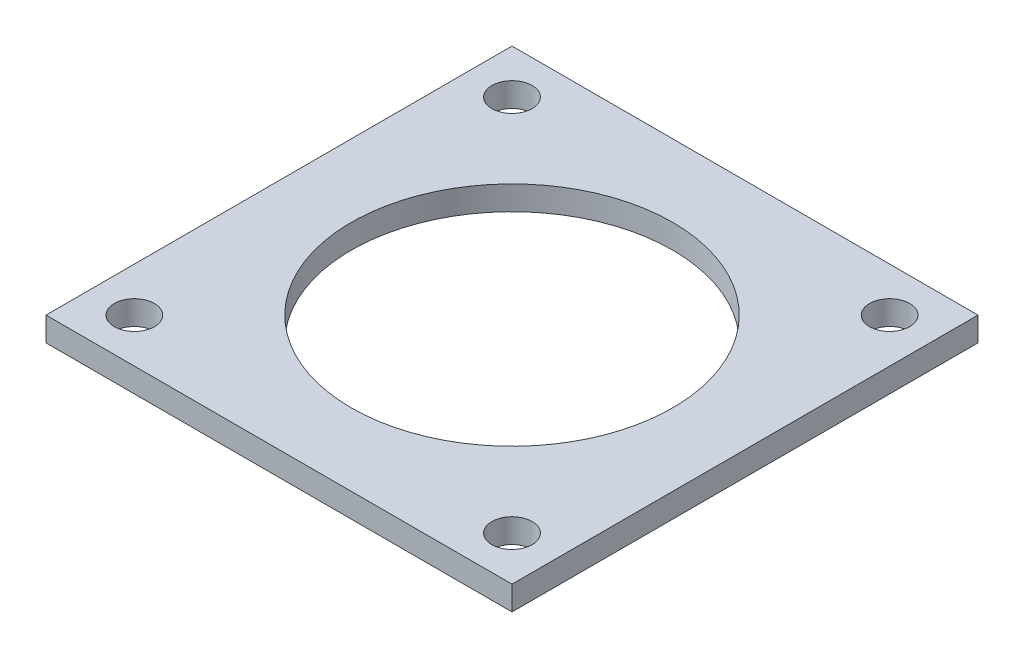
from build123d import *

# Parameters (mm, degrees)
SKETCH1_W           = 58
SKETCH1_H           = 58
SKETCH1_R           = 20
SKETCH1_R_2         = 2.5
BOSS_EXTRUDE1_DEPTH = 3


with BuildPart() as part:
    # Sketch1 → Boss-Extrude1 (new body)
    with BuildSketch(Plane(origin=(0, 0, 0), x_dir=(1, 0, 0), z_dir=(0, 1, 0))):
        with Locations((29, -29)):
            Rectangle(SKETCH1_W, SKETCH1_H)
        with Locations((29, -29)):
            Circle(SKETCH1_R, mode=Mode.SUBTRACT)
        with Locations((5.5, -5.5)):
            Circle(SKETCH1_R_2, mode=Mode.SUBTRACT)
        with Locations((52.5, -5.5)):
            Circle(SKETCH1_R_2, mode=Mode.SUBTRACT)
        with Locations((52.5, -52.5)):
            Circle(SKETCH1_R_2, mode=Mode.SUBTRACT)
        with Locations((5.5, -52.5)):
            Circle(SKETCH1_R_2, mode=Mode.SUBTRACT)
    extrude(amount=BOSS_EXTRUDE1_DEPTH)


solid = part.part
